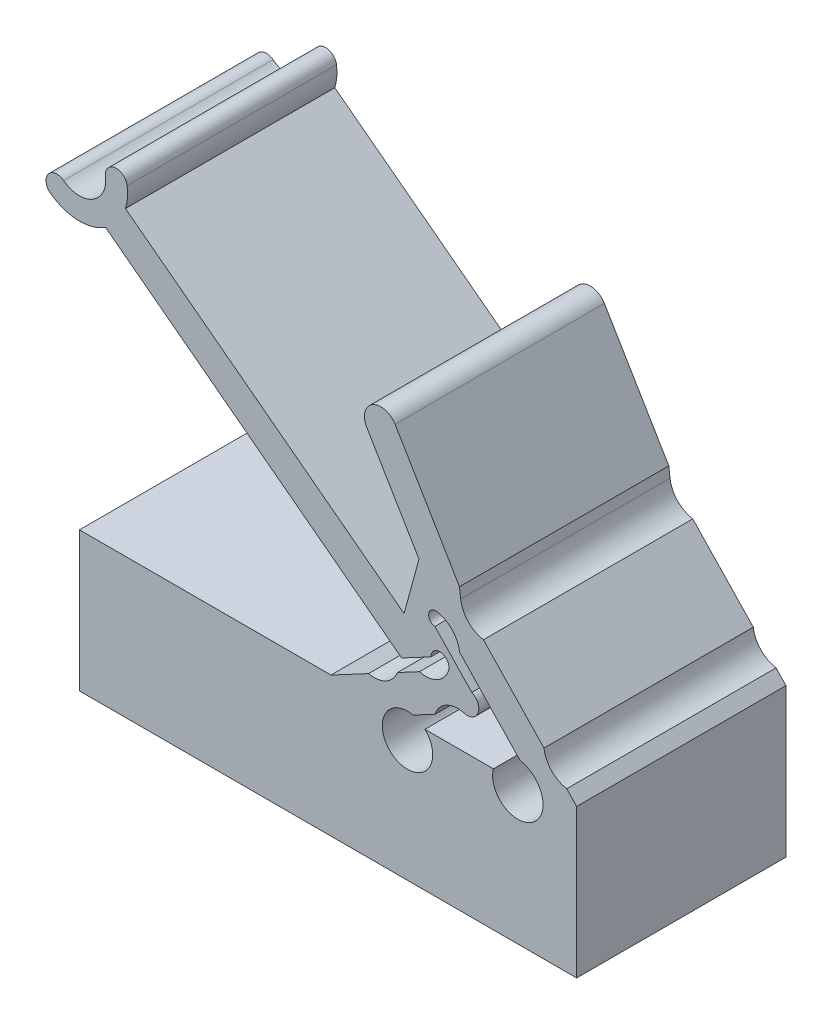
from build123d import *

# Parameters (mm, degrees)
BOSS_CONFIGDOWN_DEPTH = 9.525


with BuildPart() as part:
    # Sketch-ConfigDown → Boss-ConfigDown (new body)
    with BuildSketch(Plane.XY):
        with BuildLine():
            Line((6.361253842, 10.24597905), (8.738243229, 6.241984987))
            Line((8.738243229, 6.241984987), (8.057962434, 3.756033667))
            Line((8.057962434, 3.756033667), (-4.618320702, 13.379362796))
            ThreePointArc((-4.618320702, 13.379362796), (-4.527893169, 13.847264701), (-4.540792454, 14.323649986))
            ThreePointArc((-4.540792454, 14.323649986), (-5.103991925, 14.751208585), (-5.531550525, 14.188009115))
            ThreePointArc((-5.531550525, 14.188009115), (-6.110534003, 12.998511063), (-7.431054292, 13.078220852))
            ThreePointArc((-7.431054292, 13.078220852), (-8.131626042, 12.982308272), (-8.035713463, 12.281736522))
            ThreePointArc((-8.035713463, 12.281736522), (-6.795814255, 11.837551908), (-5.525309458, 12.184636302))
            Line((-5.525309458, 12.184636302), (7.950964943, 1.953985676))
            Line((7.950964943, 1.953985676), (9.277127849, 2.660583625))
            ThreePointArc((9.277127849, 2.660583625), (9.760085504, 3.061509958), (10.085312529, 2.524651128))
            ThreePointArc((10.085312529, 2.524651128), (9.565582424, 1.905135286), (8.761497669, 1.81930425))
            Line((8.761497669, 1.81930425), (7.764223808, 1.287942936))
            ThreePointArc((7.764223808, 1.287942936), (7.233567574, 0.688933561), (6.440408949, 0.582596058))
            Line((6.440408949, 0.582596058), (4.733705966, -0.326758911))
            Line((4.733705966, -0.326758911), (-6.711147083, -0.326758911))
            Line((-6.711147083, -0.326758911), (-6.711147083, -6.676758911))
            Line((-6.711147083, -6.676758911), (4.733705966, -6.676758911))
            Line((4.733705966, -6.676758911), (15.912367826, -6.676758911))
            Line((15.912367826, -6.676758911), (15.912367826, 0.083144011))
            Line((15.912367826, 0.083144011), (15.460918062, 0.556695121))
            ThreePointArc((15.460918062, 0.556695121), (14.76245819, 0.927037945), (14.425895986, 1.642388127))
            Line((14.425895986, 1.642388127), (11.670504731, 4.532673357))
            ThreePointArc((11.670504731, 4.532673357), (10.972044859, 4.903016181), (10.635482655, 5.618366363))
            Line((10.635482655, 5.618366363), (10.581235342, 6.075921255))
            Line((10.581235342, 6.075921255), (7.651089987, 11.011696177))
            ThreePointArc((7.651089987, 11.011696177), (6.623313351, 11.273755686), (6.361253842, 10.24597905))
        make_face()
        with BuildLine():
            Line((9.466844547, 0.495489391), (8.469570686, -0.035871924))
            ThreePointArc((8.469570686, -0.035871924), (7.676412061, -0.142209427), (7.145755827, -0.741218802))
            ThreePointArc((7.145755827, -0.741218802), (8.464824154, -2.274501403), (9.009980984, -0.326758911))
            Line((9.009980984, -0.326758911), (12.125210012, -0.326758911))
            ThreePointArc((12.125210012, -0.326758911), (13.158910635, -1.75798627), (14.375225055, -0.478326954))
            ThreePointArc((14.375225055, -0.478326954), (14.038662852, 0.237023228), (13.34020298, 0.607366052))
            Line((13.34020298, 0.607366052), (10.584811724, 3.497651281))
            ThreePointArc((10.584811724, 3.497651281), (10.248249521, 4.213001464), (9.549789649, 4.583344288))
            ThreePointArc((9.549789649, 4.583344288), (9.181503481, 4.313482225), (9.460673669, 3.952200837))
            Line((9.460673669, 3.952200837), (10.970207057, 2.368766163))
            Line((10.970207057, 2.368766163), (11.140648168, 2.189980874))
            ThreePointArc((11.140648168, 2.189980874), (11.42991126, 1.531140478), (10.790659406, 1.200836268))
            ThreePointArc((10.790659406, 1.200836268), (9.986574651, 1.115005233), (9.466844547, 0.495489391))
        make_face(mode=Mode.SUBTRACT)
    extrude(amount=BOSS_CONFIGDOWN_DEPTH)


solid = part.part
